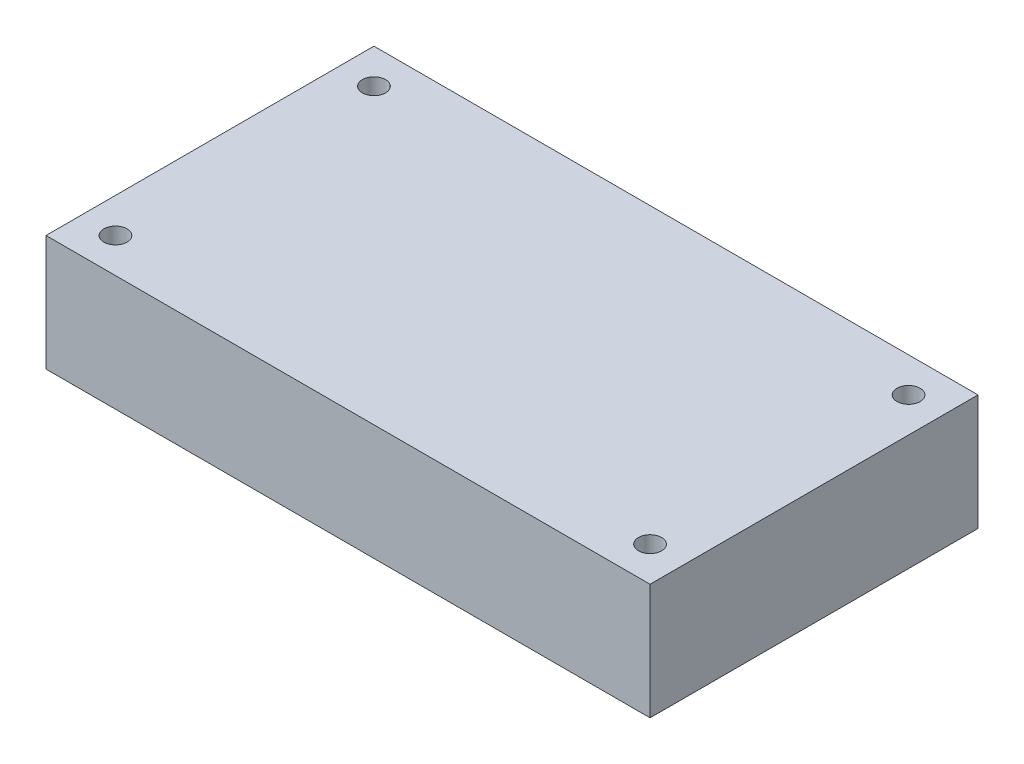
from build123d import *

# Parameters (mm, degrees)
SKETCH3_W           = 66.294
SKETCH3_H           = 35.9918
SKETCH3_R           = 1.27
BOSS_EXTRUDE1_DEPTH = 12.7


with BuildPart() as part:
    # Sketch3 → Boss-Extrude1 (new body)
    with BuildSketch(Plane(origin=(0, 0, 0), x_dir=(1, 0, 0), z_dir=(0, 1, 0))):
        Rectangle(SKETCH3_W, SKETCH3_H)
        with Locations((-29.337, 14.1859)):
            Circle(SKETCH3_R, mode=Mode.SUBTRACT)
        with Locations((29.337, 14.1859)):
            Circle(SKETCH3_R, mode=Mode.SUBTRACT)
        with Locations((29.337, -14.1859)):
            Circle(SKETCH3_R, mode=Mode.SUBTRACT)
        with Locations((-29.337, -14.1859)):
            Circle(SKETCH3_R, mode=Mode.SUBTRACT)
    extrude(amount=BOSS_EXTRUDE1_DEPTH)


solid = part.part
